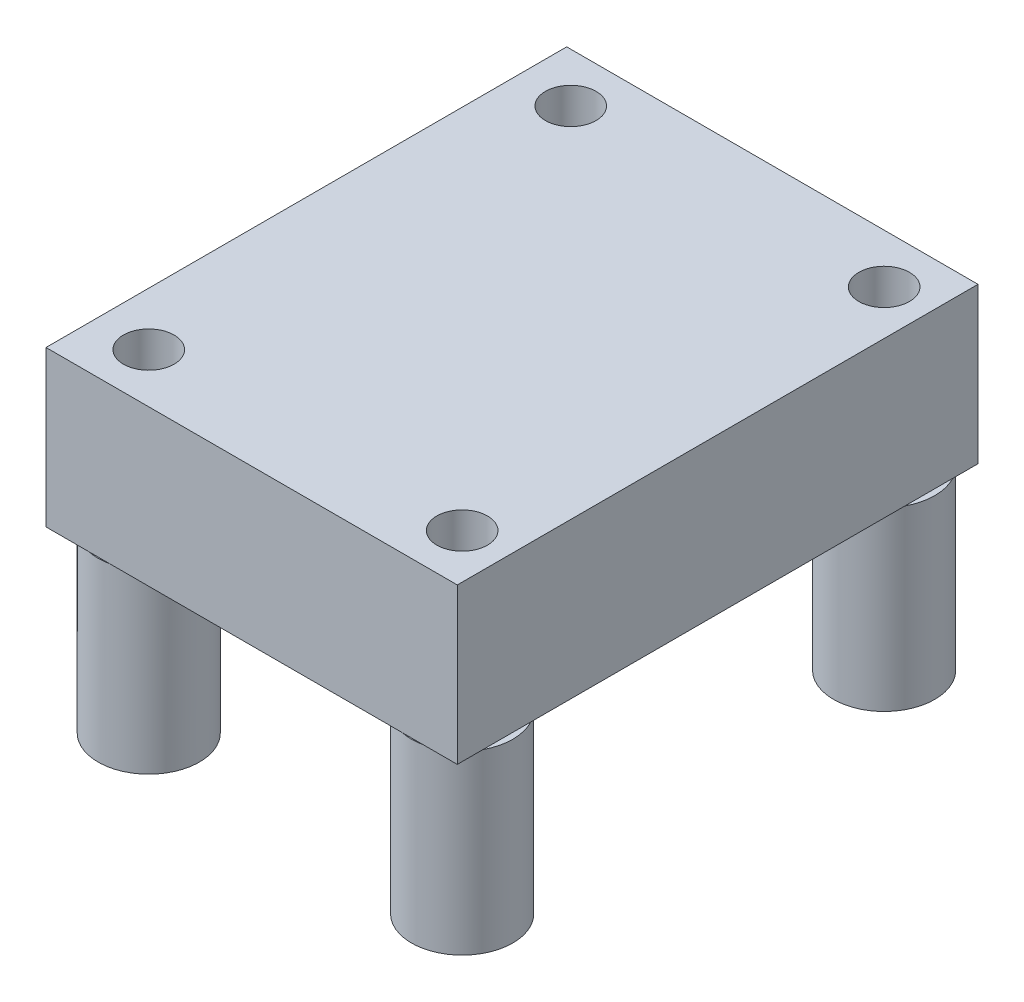
from build123d import *

# Parameters (mm, degrees)
SKETCH1_W               = 20.3
SKETCH1_H               = 25.7
BOSS_EXTRUDE1_DEPTH     = 7.6708
SKETCH2_R               = 2.5
SKETCH2_R_2             = 1.25
BOSS_EXTRUDE2_DEPTH     = 8.7122
CUT_EXTRUDE1_DEPTH      = 27.682326303
CUT_EXTRUDE1_DEPTH_BACK = 27.682326303
SKETCH3_R               = 1.25


with BuildPart() as part:
    # Sketch1 → Boss-Extrude1 (new body)
    with BuildSketch(Plane(origin=(0, 0, 0), x_dir=(1, 0, 0), z_dir=(0, 1, 0))):
        with Locations((0.979781162, -4.787001603)):
            Rectangle(SKETCH1_W, SKETCH1_H)
    extrude(amount=BOSS_EXTRUDE1_DEPTH)

    # Sketch2 → Boss-Extrude2 (add)
    # profile 1 of 4: a face of its own
    with BuildSketch(Plane(origin=(0, 0, 0), x_dir=(-1, 0, 0), z_dir=(0, -1, 0))):
        with Locations(Location((6.543467427, -15.1920941, 0), (0, 0, 282.050765662))):
            Circle(SKETCH2_R)
        with Locations(Location((6.543467427, -15.1920941, 0), (0, 0, 90))):
            Circle(SKETCH2_R_2, mode=Mode.SUBTRACT)
    # profile 2 of 4: a face of its own
    with BuildSketch(Plane(origin=(0, 0, 0), x_dir=(-1, 0, 0), z_dir=(0, -1, 0))):
        with Locations(Location((-8.925132573, -15.1920941, 0), (0, 0, 257.949234338))):
            Circle(SKETCH2_R)
        with Locations(Location((-8.925132573, -15.1920941, 0), (0, 0, 90))):
            Circle(SKETCH2_R_2, mode=Mode.SUBTRACT)
    # profile 3 of 4: a face of its own
    with BuildSketch(Plane(origin=(0, 0, 0), x_dir=(-1, 0, 0), z_dir=(0, -1, 0))):
        with Locations(Location((-8.925132573, 5.6359059, 0), (0, 0, 208.132514033))):
            Circle(SKETCH2_R)
        with Locations(Location((-8.925132573, 5.6359059, 0), (0, 0, 90))):
            Circle(SKETCH2_R_2, mode=Mode.SUBTRACT)
    # profile 4 of 4: a face of its own
    with BuildSketch(Plane(origin=(0, 0, 0), x_dir=(-1, 0, 0), z_dir=(0, -1, 0))):
        with Locations(Location((6.543467427, 5.6359059, 0), (0, 0, 76.12877324))):
            Circle(SKETCH2_R)
        with Locations(Location((6.543467427, 5.6359059, 0), (0, 0, 90))):
            Circle(SKETCH2_R_2, mode=Mode.SUBTRACT)
    extrude(amount=BOSS_EXTRUDE2_DEPTH)

    # Sketch3 → Cut-Extrude1 (cut, two sides: drawn at the far end of the back side and taken through both)
    with BuildSketch(Plane(origin=(0, 7.6708, 0), x_dir=(1, 0, 0), z_dir=(0, 1, 0)).offset(-CUT_EXTRUDE1_DEPTH_BACK)):
        with Locations(Location((8.925132573, 5.6359059, 0), (0, 0, 270))):
            Circle(SKETCH3_R)
        with Locations(Location((-6.543467427, 5.6359059, 0), (0, 0, 270))):
            Circle(SKETCH3_R)
        with Locations(Location((8.925132573, -15.1920941, 0), (0, 0, 270))):
            Circle(SKETCH3_R)
        with Locations(Location((-6.543467427, -15.1920941, 0), (0, 0, 270))):
            Circle(SKETCH3_R)
    extrude(amount=CUT_EXTRUDE1_DEPTH + CUT_EXTRUDE1_DEPTH_BACK, mode=Mode.SUBTRACT)


solid = part.part
